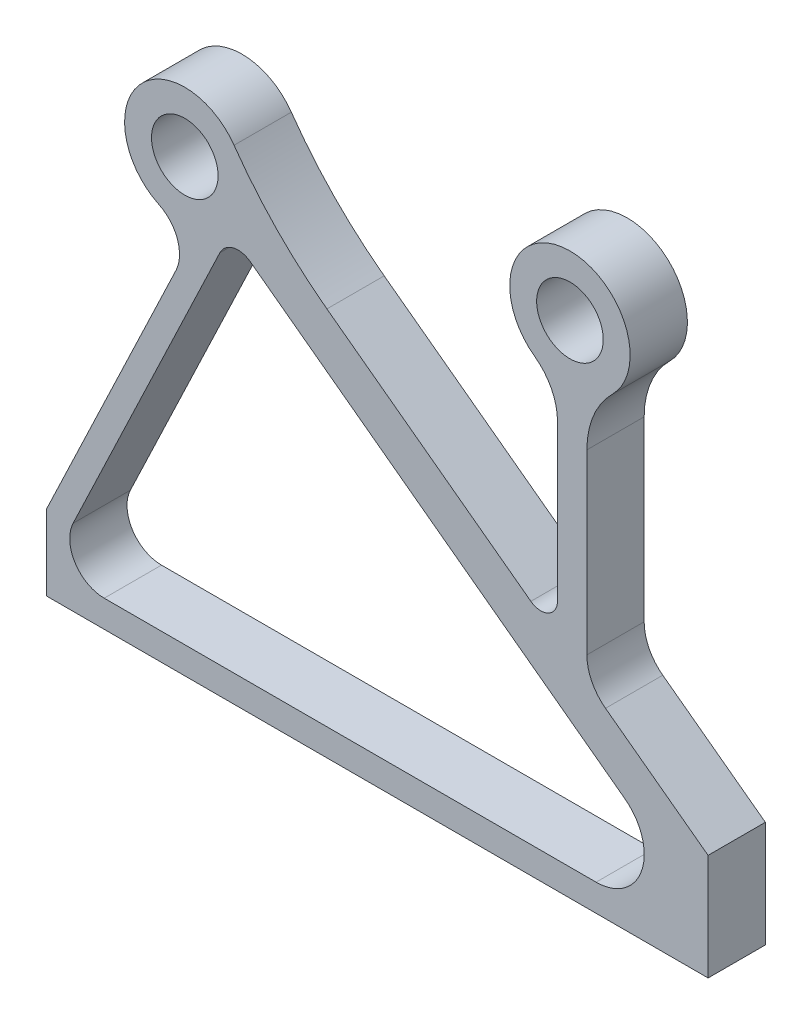
from build123d import *

# Parameters (mm, degrees)
SZKIC2_R                    = 23.25
DODANIE_WYCI_GNI_CIE2_DEPTH = 40


with BuildPart() as part:
    # Szkic2 → Dodanie-wyciągnięcie2 (new body)
    with BuildSketch(Plane.XY):
        with BuildLine():
            Line((356.808690949, 284.085111344), (356.808690949, 175.310171823))
            ThreePointArc((356.808690949, 175.310171823), (350.393476668, 164.898302535), (338.208931835, 165.946569461))
            Line((338.208931835, 165.946569461), (195.757922755, 271.57137534))
            ThreePointArc((195.757922755, 271.57137534), (160.658297297, 302.249297223), (130.912486716, 338.142268))
            ThreePointArc((130.912486716, 338.142268), (64.422832686, 341.168431743), (78.350481289, 276.083469083))
            ThreePointArc((78.350481289, 276.083469083), (91.368118976, 261.595098554), (90.340641348, 242.144749939))
            Line((90.340641348, 242.144749939), (0, 52.788302942))
            Line((0, 52.788302942), (0, 0))
            Line((0, 0), (462, 0))
            Line((462, 0), (461.978142717, 74.173973692))
            Line((461.978142717, 74.173973692), (390.329817514, 127.299890384))
            ThreePointArc((390.329817514, 127.299890384), (380.765620141, 138.664659162), (377.333162938, 153.116305376))
            Line((377.333162938, 153.116305376), (377.333162938, 277.104406009))
            ThreePointArc((377.333162938, 277.104406009), (381.945835927, 300.14062202), (395.072603756, 319.624768565))
            ThreePointArc((395.072603756, 319.624768565), (362.301076624, 391.414618398), (340.803653738, 315.482962688))
            ThreePointArc((340.803653738, 315.482962688), (352.576627129, 301.70602424), (356.808690949, 284.085111344))
        make_face()
        with Locations((96.5, 314)):
            Circle(SZKIC2_R, mode=Mode.SUBTRACT)
        with Locations((365.5, 349.5)):
            Circle(SZKIC2_R, mode=Mode.SUBTRACT)
        with BuildLine():
            Line((142.210331035, 273.398097089), (403.788200613, 79.442912954))
            ThreePointArc((403.788200613, 79.442912954), (415.683061467, 41.906486457), (383.77111031, 18.839228227))
            Line((383.77111031, 18.839228227), (40.223377682, 18.839228227))
            ThreePointArc((40.223377682, 18.839228227), (19.858572573, 30.070249276), (18.491115014, 53.286432871))
            Line((18.491115014, 53.286432871), (120.985954342, 268.118410164))
            ThreePointArc((120.985954342, 268.118410164), (130.352396717, 275.766160753), (142.210331035, 273.398097089))
        make_face(mode=Mode.SUBTRACT)
    extrude(amount=DODANIE_WYCI_GNI_CIE2_DEPTH)


solid = part.part
